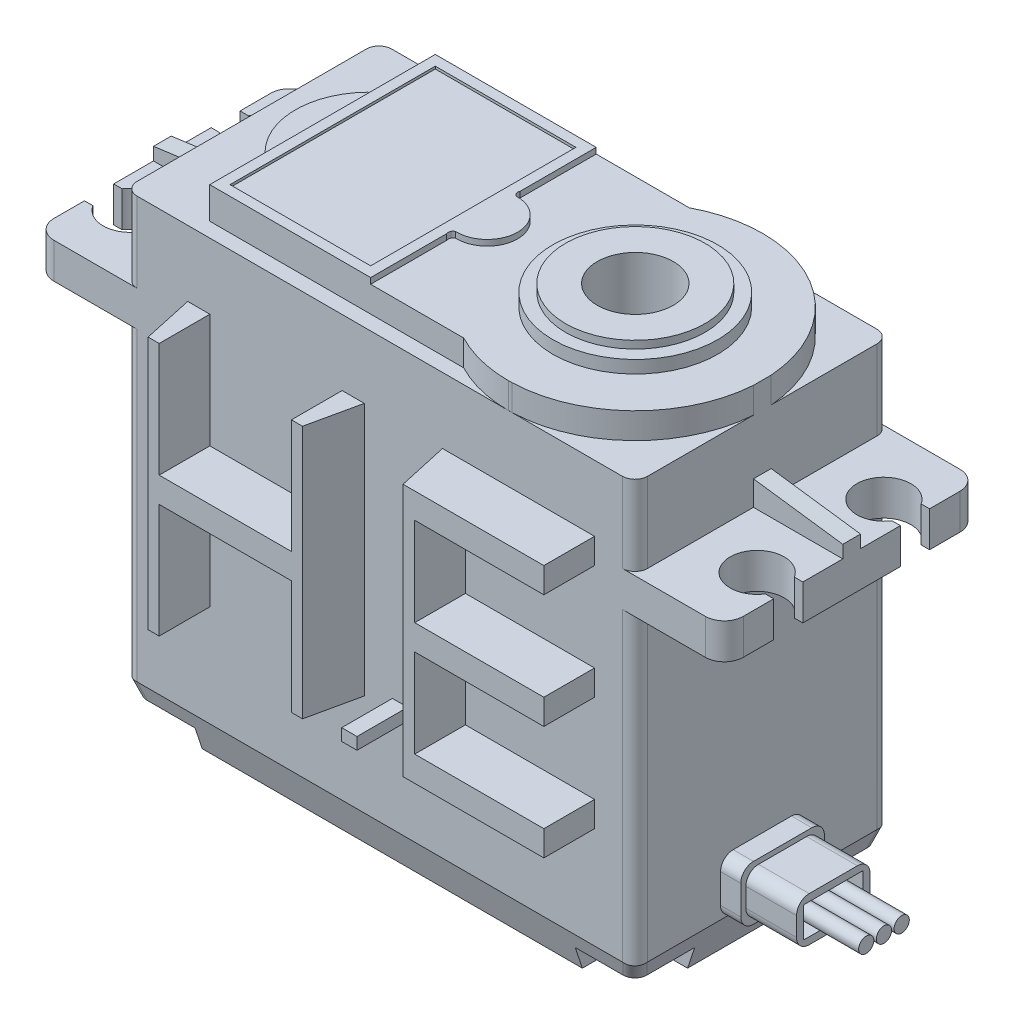
from build123d import *

# Parameters (mm, degrees)
Y_KSEKLIK_EKSTR_ZYON1_DEPTH      = 20.1
Y_KSEKLIK_EKSTR_ZYON2_DEPTH      = 0.7
Y_KSEKLIK_EKSTR_ZYON2_DEPTH_BACK = 0.7
KES_EKSTR_ZYON2_DEPTH            = 50
RADYUS1_R                        = 1.5
RADYUS2_R                        = 1
KES_EKSTR_ZYON4_DEPTH            = 2.5
KES_EKSTR_ZYON6_DEPTH            = 0.4
KES_EKSTR_ZYON7_DEPTH            = 0.46
KES_EKSTR_ZYON8_DEPTH            = 2.5
IZIM10_W                         = 9
IZIM10_H                         = 2.5
KES_EKSTR_ZYON9_DEPTH            = 0.005
IZIM11_W                         = 11.1
IZIM11_H                         = 16.2
KES_EKSTR_ZYON10_DEPTH           = 0.2
IZIM12_R                         = 6.5
IZIM12_R_2                       = 5.5
Y_KSEKLIK_EKSTR_ZYON3_DEPTH      = 1
IZIM13_R                         = 5.5
Y_KSEKLIK_EKSTR_ZYON4_DEPTH      = 1.6
IZIM14_R                         = 3
KES_EKSTR_ZYON11_DEPTH           = 10
KES_EKSTR_ZYON12_DEPTH           = 50
KES_EKSTR_ZYON13_DEPTH           = 50
RADYUS3_R                        = 1
KES_EKSTR_ZYON14_DEPTH           = 1.7
IZIM20_R                         = 1.35
KES_EKSTR_ZYON15_DEPTH           = 32
IZIM21_W                         = 6.6
IZIM21_H                         = 4.3
Y_KSEKLIK_EKSTR_ZYON5_DEPTH      = 1.6
RADYUS4_R                        = 1
IZIM22_W                         = 5.8
IZIM22_H                         = 3.5
Y_KSEKLIK_EKSTR_ZYON6_DEPTH      = 4
RADYUS6_R                        = 1
IZIM23_W                         = 4.7
IZIM23_H                         = 2.4
KES_EKSTR_ZYON17_DEPTH           = 4
RADYUS7_R                        = 0.1
IZIM24_R                         = 0.6
Y_KSEKLIK_EKSTR_ZYON7_DEPTH      = 8
IZIM25_W                         = 1.206415868
IZIM25_H                         = 0.943780888
Y_KSEKLIK_EKSTR_ZYON9_DEPTH      = 4
KES_EKSTR_ZYON18_DEPTH           = 21
KES_EKSTR_ZYON19_DEPTH           = 21


with BuildPart() as part:
    # Çizim1 → Yükseklik-Ekstrüzyon1 (new body)
    with BuildSketch(Plane.XY):
        Polygon((-48.759292093, -35.698320222), (-8.459292093, -35.698320222), (-8.459292093, -8.598320222), (-1.409292093, -8.598320222), (-1.409292093, -5.798320222), (-8.459292093, -5.798320222), (-8.459292093, 3.001679778), (-48.759292093, 3.001679778), (-48.759292093, -5.798320222), (-55.809292093, -5.798320222), (-55.809292093, -8.598320222), (-48.759292093, -8.598320222), align=None)
    extrude(amount=Y_KSEKLIK_EKSTR_ZYON1_DEPTH)

    # Çizim3 → Yükseklik-Ekstrüzyon2 (add, two sides)
    with BuildSketch(Plane.XY.offset(10.05)) as y_kseklik_ekstr_zyon2_sk:
        Polygon((-55.809292093, -5.798320222), (-48.759292093, -5.798320222), (-48.759292093, -3.848320222), (-55.809292093, -4.798320222), align=None)
        Polygon((-8.459292093, -5.798320222), (-1.409292093, -5.798320222), (-1.409292093, -4.798320222), (-8.459292093, -3.848320222), align=None)
    extrude(amount=Y_KSEKLIK_EKSTR_ZYON2_DEPTH)
    extrude(y_kseklik_ekstr_zyon2_sk.sketch, amount=-Y_KSEKLIK_EKSTR_ZYON2_DEPTH_BACK)

    # Çizim4 → Kes-Ekstrüzyon2 (cut)
    with BuildSketch(Plane(origin=(0, 3.001679778, 0), x_dir=(1, 0, 0), z_dir=(0, 1, 0))):
        with BuildLine():
            Line((-55.809292093, -16.2), (-55.146292093, -16.2))
            ThreePointArc((-55.146292093, -16.2), (-51.225748416, -15.04637383), (-55.146292093, -13.892747659))
            Line((-55.146292093, -13.892747659), (-55.809292093, -13.892747659))
            Line((-55.809292093, -13.892747659), (-55.809292093, -16.2))
        make_face()
        with BuildLine():
            Line((-55.809292093, -3.916330706), (-55.146292093, -3.916330706))
            ThreePointArc((-55.146292093, -3.916330706), (-51.218205988, -5.058165353), (-55.146292093, -6.2))
            Line((-55.146292093, -6.2), (-55.809292093, -6.2))
            Line((-55.809292093, -6.2), (-55.809292093, -3.916330706))
        make_face()
        with BuildLine():
            Line((-1.409292093, -6.2), (-2.072292093, -6.2))
            ThreePointArc((-2.072292093, -6.2), (-5.995166879, -5.05), (-2.072292093, -3.9))
            Line((-2.072292093, -3.9), (-1.409292093, -3.9))
            Line((-1.409292093, -3.9), (-1.409292093, -6.2))
        make_face()
        with BuildLine():
            Line((-1.409292093, -13.902170696), (-2.072292093, -13.902170696))
            ThreePointArc((-2.072292093, -13.902170696), (-5.995862588, -15.051085348), (-2.072292093, -16.2))
            Line((-2.072292093, -16.2), (-1.409292093, -16.2))
            Line((-1.409292093, -16.2), (-1.409292093, -13.902170696))
        make_face()
    extrude(amount=-KES_EKSTR_ZYON2_DEPTH, mode=Mode.SUBTRACT)

    # Radyus1
    radyus1_edges = [part.edges().sort_by_distance(p)[0] for p in [
        (-1.409292093, -7.198320222, 20.1),
        (-55.809292093, -7.198320222, 0),
        (-1.409292093, -7.198320222, 0),
        (-55.809292093, -7.198320222, 20.1),
    ]]
    fillet(radyus1_edges, radius=RADYUS1_R)

    # Radyus2
    radyus2_edges = [part.edges().sort_by_distance(p)[0] for p in [
        (-48.759292093, -22.148320222, 0),
        (-48.759292093, -1.398320222, 0),
        (-8.459292093, -1.398320222, 0),
        (-8.459292093, -22.148320222, 0),
        (-8.459292093, -1.398320222, 20.1),
        (-48.759292093, -1.398320222, 20.1),
        (-48.759292093, -22.148320222, 20.1),
        (-8.459292093, -22.148320222, 20.1),
    ]]
    fillet(radyus2_edges, radius=RADYUS2_R)

    # Çizim5 → Kes-Ekstrüzyon4 (cut)
    with BuildSketch(Plane(origin=(0, 3.001679778, 0), x_dir=(1, 0, 0), z_dir=(0, 1, 0))):
        with BuildLine():
            ThreePointArc((-23.127535874, -1.15), (-20.863195169, -0.291734273), (-18.459292093, 0))
            Line((-18.459292093, 0), (-47.759292093, 0))
            ThreePointArc((-47.759292093, 0), (-48.466398874, -0.292893219), (-48.759292093, -1))
            Line((-48.759292093, -1), (-48.759292093, -19.1))
            ThreePointArc((-48.759292093, -19.1), (-48.466398874, -19.807106781), (-47.759292093, -20.1))
            Line((-47.759292093, -20.1), (-18.459292093, -20.1))
            ThreePointArc((-18.459292093, -20.1), (-20.863195169, -19.808265727), (-23.127535874, -18.95))
            Line((-23.127535874, -18.95), (-43.170310905, -18.95))
            Line((-43.170310905, -18.95), (-43.170310905, -14.54))
            ThreePointArc((-43.170310905, -14.54), (-45.305060631, -10.05), (-43.170310905, -5.56))
            Line((-43.170310905, -5.56), (-43.170310905, -1.15))
            Line((-43.170310905, -1.15), (-23.127535874, -1.15))
        make_face()
    extrude(amount=-KES_EKSTR_ZYON4_DEPTH, mode=Mode.SUBTRACT)

    # Çizim7 → Kes-Ekstrüzyon6 (cut)
    with BuildSketch(Plane(origin=(0, 3.001679778, 0), x_dir=(1, 0, 0), z_dir=(0, 1, 0))):
        with BuildLine():
            Line((-43.170310905, -5.56), (-43.170310905, -14.54))
            ThreePointArc((-43.170310905, -14.54), (-45.305060631, -10.05), (-43.170310905, -5.56))
        make_face()
    extrude(amount=-KES_EKSTR_ZYON6_DEPTH, mode=Mode.SUBTRACT)

    # Çizim8 → Kes-Ekstrüzyon7 (cut)
    with BuildSketch(Plane(origin=(0, 3.001679778, 0), x_dir=(1, 0, 0), z_dir=(0, 1, 0))):
        with BuildLine():
            Line((-30.470310905, -1.15), (-23.127535874, -1.15))
            ThreePointArc((-23.127535874, -1.15), (-8.409292093, -10.05), (-23.127535874, -18.95))
            Line((-23.127535874, -18.95), (-30.470310905, -18.95))
            Line((-30.470310905, -18.95), (-30.470310905, -12.945))
            ThreePointArc((-30.470310905, -12.945), (-30.47115449, -12.654263301), (-30.266169104, -12.448084904))
            ThreePointArc((-30.266169104, -12.448084904), (-27.770310905, -10.05), (-30.266169104, -7.651915096))
            ThreePointArc((-30.266169104, -7.651915096), (-30.47115449, -7.445736699), (-30.470310905, -7.155))
            Line((-30.470310905, -7.155), (-30.470310905, -1.15))
        make_face()
    extrude(amount=-KES_EKSTR_ZYON7_DEPTH, mode=Mode.SUBTRACT)

    # Çizim9 → Kes-Ekstrüzyon8 (cut)
    with BuildSketch(Plane(origin=(0, 3.001679778, 0), x_dir=(1, 0, 0), z_dir=(0, 1, 0))):
        with BuildLine():
            Line((-18.459292093, 0), (-8.459292093, 0))
            Line((-8.459292093, 0), (-8.459292093, -9.35))
            ThreePointArc((-8.459292093, -9.35), (-11.621052025, -2.708967842), (-18.459292093, 0))
        make_face()
        with BuildLine():
            Line((-8.459292093, -20.099934818), (-8.459292093, -10.749934818))
            ThreePointArc((-8.459292093, -10.749934818), (-11.621052025, -17.390966976), (-18.459292093, -20.099934818))
            Line((-18.459292093, -20.099934818), (-8.459292093, -20.099934818))
        make_face()
    extrude(amount=-KES_EKSTR_ZYON8_DEPTH, mode=Mode.SUBTRACT)

    # Çizim10 → Kes-Ekstrüzyon9 (cut)
    with BuildSketch(Plane.XY.offset(20.1)):
        with Locations((-13.959292093, 1.751679778)):
            Rectangle(IZIM10_W, IZIM10_H)
    extrude(amount=-KES_EKSTR_ZYON9_DEPTH, mode=Mode.SUBTRACT)

    # Çizim11 → Kes-Ekstrüzyon10 (cut)
    with BuildSketch(Plane(origin=(0, 3.001679778, 0), x_dir=(1, 0, 0), z_dir=(0, 1, 0))):
        with Locations((-36.820310905, -10.05)):
            Rectangle(IZIM11_W, IZIM11_H)
    extrude(amount=-KES_EKSTR_ZYON10_DEPTH, mode=Mode.SUBTRACT)

    # Çizim12 → Yükseklik-Ekstrüzyon3 (add)
    with BuildSketch(Plane(origin=(0, 2.541679778, 0), x_dir=(1, 0, 0), z_dir=(0, 1, 0))):
        with Locations((-18.48488662, -10.049967409)):
            Circle(IZIM12_R)
        with Locations((-18.48488662, -10.049967409)):
            Circle(IZIM12_R_2, mode=Mode.SUBTRACT)
    extrude(amount=Y_KSEKLIK_EKSTR_ZYON3_DEPTH)

    # Çizim13 → Yükseklik-Ekstrüzyon4 (add)
    with BuildSketch(Plane(origin=(0, 2.541679778, 0), x_dir=(1, 0, 0), z_dir=(0, 1, 0))):
        with Locations((-18.48488662, -10.049967409)):
            Circle(IZIM13_R)
    extrude(amount=Y_KSEKLIK_EKSTR_ZYON4_DEPTH)

    # Çizim14 → Kes-Ekstrüzyon11 (cut)
    with BuildSketch(Plane(origin=(0, 4.141679778, 0), x_dir=(1, 0, 0), z_dir=(0, 1, 0))):
        with Locations((-18.48488662, -10.049967409)):
            Circle(IZIM14_R)
    extrude(amount=-KES_EKSTR_ZYON11_DEPTH, mode=Mode.SUBTRACT)

    # Çizim15 → Kes-Ekstrüzyon12 (cut)
    with BuildSketch(Plane.ZY.offset(48.759292093)):
        Polygon((20.1, -35.698320222), (20.1, -32.698320222), (19.1, -35.698320222), align=None)
        Polygon((0, -35.698320222), (1, -35.698320222), (0, -32.698320222), align=None)
    extrude(amount=-KES_EKSTR_ZYON12_DEPTH, mode=Mode.SUBTRACT)

    # Çizim17 → Kes-Ekstrüzyon13 (cut)
    with BuildSketch(Plane.XY.offset(20.1)):
        Polygon((-48.759292093, -32.698320222), (-48.759292093, -35.698320222), (-47.759292093, -35.698320222), align=None)
        Polygon((-8.459292093, -35.698320222), (-9.459292093, -35.698320222), (-8.459292093, -32.698320222), align=None)
    extrude(amount=-KES_EKSTR_ZYON13_DEPTH, mode=Mode.SUBTRACT)

    # Radyus3
    radyus3_edges = [part.edges().sort_by_distance(p)[0] for p in [
        (-9.105738702, -34.63766005, 0.646446609),
        (-48.112845483, -34.63766005, 0.646446609),
        (-9.105738702, -34.63766005, 19.453553391),
        (-48.112845483, -34.63766005, 19.453553391),
    ]]
    fillet(radyus3_edges, radius=RADYUS3_R)

    # Çizim18 → Kes-Ekstrüzyon14 (cut)
    with BuildSketch(Plane.XZ.offset(35.698320222)):
        with BuildLine():
            Line((-48.759292093, 20.1), (-43.609292093, 20.1))
            Line((-43.609292093, 20.1), (-43.609292093, 17.6))
            ThreePointArc((-43.609292093, 17.6), (-44.385459123, 15.72616703), (-46.259292093, 14.95))
            Line((-46.259292093, 14.95), (-48.759292093, 14.95))
            Line((-48.759292093, 14.95), (-48.759292093, 20.1))
        make_face()
        with BuildLine():
            Line((-48.759292093, 5.15), (-46.259292093, 5.15))
            ThreePointArc((-46.259292093, 5.15), (-44.385459123, 4.37383297), (-43.609292093, 2.5))
            Line((-43.609292093, 2.5), (-43.609292093, 0))
            Line((-43.609292093, 0), (-48.759292093, 0))
            Line((-48.759292093, 0), (-48.759292093, 5.15))
        make_face()
        with BuildLine():
            Line((-8.459292093, 14.95), (-10.959292093, 14.95))
            ThreePointArc((-10.959292093, 14.95), (-12.833125063, 15.72616703), (-13.609292093, 17.6))
            Line((-13.609292093, 17.6), (-13.609292093, 20.1))
            Line((-13.609292093, 20.1), (-8.459292093, 20.1))
            Line((-8.459292093, 20.1), (-8.459292093, 14.95))
        make_face()
        with BuildLine():
            Line((-8.459292093, 0), (-13.609292093, 0))
            Line((-13.609292093, 0), (-13.609292093, 2.5))
            ThreePointArc((-13.609292093, 2.5), (-12.833125063, 4.37383297), (-10.959292093, 5.15))
            Line((-10.959292093, 5.15), (-8.459292093, 5.15))
            Line((-8.459292093, 5.15), (-8.459292093, 0))
        make_face()
    extrude(amount=-KES_EKSTR_ZYON14_DEPTH, mode=Mode.SUBTRACT)

    # Çizim20 → Kes-Ekstrüzyon15 (cut)
    with BuildSketch(Plane(origin=(0, -33.998320222, 0), x_dir=(-1, 0, 0), z_dir=(0, -1, 0))):
        with Locations((46.259292093, -2.5)):
            Circle(IZIM20_R)
        with Locations((10.959292093, -17.6)):
            Circle(IZIM20_R)
        with Locations((10.959292093, -2.5)):
            Circle(IZIM20_R)
        with Locations((46.259292093, -17.6)):
            Circle(IZIM20_R)
    extrude(amount=-KES_EKSTR_ZYON15_DEPTH, mode=Mode.SUBTRACT)

    # Çizim21 → Yükseklik-Ekstrüzyon5 (add)
    with BuildSketch(Plane(origin=(-8.459292093, 0, 0), x_dir=(0, 0, -1), z_dir=(1, 0, 0))):
        with Locations((-10.05, -30.548320222)):
            Rectangle(IZIM21_W, IZIM21_H)
    extrude(amount=Y_KSEKLIK_EKSTR_ZYON5_DEPTH)

    # Radyus4
    radyus4_edges = [part.edges().sort_by_distance(p)[0] for p in [
        (-7.659292093, -28.398320222, 13.35),
        (-7.659292093, -32.698320222, 13.35),
        (-7.659292093, -32.698320222, 6.75),
        (-7.659292093, -28.398320222, 6.75),
    ]]
    fillet(radyus4_edges, radius=RADYUS4_R)

    # Çizim22 → Yükseklik-Ekstrüzyon6 (add)
    with BuildSketch(Plane(origin=(-6.859292093, 0, 0), x_dir=(0, 0, -1), z_dir=(1, 0, 0))):
        with Locations((-10.05, -30.548320222)):
            Rectangle(IZIM22_W, IZIM22_H)
    extrude(amount=Y_KSEKLIK_EKSTR_ZYON6_DEPTH)

    # Radyus6
    radyus6_edges = [part.edges().sort_by_distance(p)[0] for p in [
        (-4.859292093, -28.798320222, 12.95),
        (-4.859292093, -32.298320222, 12.95),
        (-4.859292093, -32.298320222, 7.15),
        (-4.859292093, -28.798320222, 7.15),
    ]]
    fillet(radyus6_edges, radius=RADYUS6_R)

    # Çizim23 → Kes-Ekstrüzyon17 (cut)
    with BuildSketch(Plane(origin=(-2.859292093, 0, 0), x_dir=(0, 0, -1), z_dir=(1, 0, 0))):
        with Locations((-10.05, -30.548320222)):
            Rectangle(IZIM23_W, IZIM23_H)
    extrude(amount=-KES_EKSTR_ZYON17_DEPTH, mode=Mode.SUBTRACT)

    # Radyus7
    radyus7_edges = [part.edges().sort_by_distance(p)[0] for p in [
        (-4.859292093, -31.748320222, 7.7),
        (-4.859292093, -29.348320222, 7.7),
        (-4.859292093, -29.348320222, 12.4),
        (-4.859292093, -31.748320222, 12.4),
    ]]
    fillet(radyus7_edges, radius=RADYUS7_R)

    # Çizim24 → Yükseklik-Ekstrüzyon7 (add)
    with BuildSketch(Plane(origin=(-6.859292093, 0, 0), x_dir=(0, 0, -1), z_dir=(1, 0, 0))):
        with Locations((-11.45, -30.548320222)):
            Circle(IZIM24_R)
        with Locations((-10.05, -30.548320222)):
            Circle(IZIM24_R)
        with Locations((-8.65, -30.548320222)):
            Circle(IZIM24_R)
    extrude(amount=Y_KSEKLIK_EKSTR_ZYON7_DEPTH)

    # Çizim25 → Yükseklik-Ekstrüzyon9 (add)
    with BuildSketch(Plane.XY.offset(20.1)):
        Polygon((-42.009292093, -4.698320222), (-43.759292093, -4.698320222), (-43.759292093, -24.698320222), (-42.009292093, -24.698320222), (-42.009292093, -15.698320222), (-31.57095661, -15.698320222), (-31.57095661, -24.698320222), (-29.82095661, -24.698320222), (-29.82095661, -4.698320222), (-31.57095661, -4.698320222), (-31.57095661, -13.698320222), (-42.009292093, -13.698320222), align=None)
        Polygon((-23.650727803, -4.698320222), (-23.650727803, -24.682169673), (-11.650727803, -24.682169673), (-11.650727803, -22.682169673), (-21.841104001, -22.682169673), (-21.841104001, -15.698320222), (-11.650727803, -15.698320222), (-11.650727803, -13.698320222), (-21.841104001, -13.698320222), (-21.841104001, -6.698320222), (-11.650727803, -6.698320222), (-11.650727803, -4.698320222), align=None)
        with Locations((-26.999018569, -24.226429778)):
            Rectangle(IZIM25_W, IZIM25_H)
    extrude(amount=Y_KSEKLIK_EKSTR_ZYON9_DEPTH)

    # Çizim26 → Kes-Ekstrüzyon18 (cut)
    with BuildSketch(Plane.XZ.offset(24.698320222)):
        Polygon((-43.759292093, 24.1), (-43.759292093, 20.1), (-42.884292093, 24.1), align=None)
        Polygon((-30.69595661, 24.1), (-29.82095661, 24.1), (-29.82095661, 20.1), align=None)
    extrude(amount=-KES_EKSTR_ZYON18_DEPTH, mode=Mode.SUBTRACT)

    # Çizim27 → Kes-Ekstrüzyon19 (cut)
    with BuildSketch(Plane.XZ.offset(24.682169673)):
        Polygon((-23.650727803, 24.1), (-22.763582783, 24.1), (-23.650727803, 20.1), align=None)
    extrude(amount=-KES_EKSTR_ZYON19_DEPTH, mode=Mode.SUBTRACT)


solid = part.part
